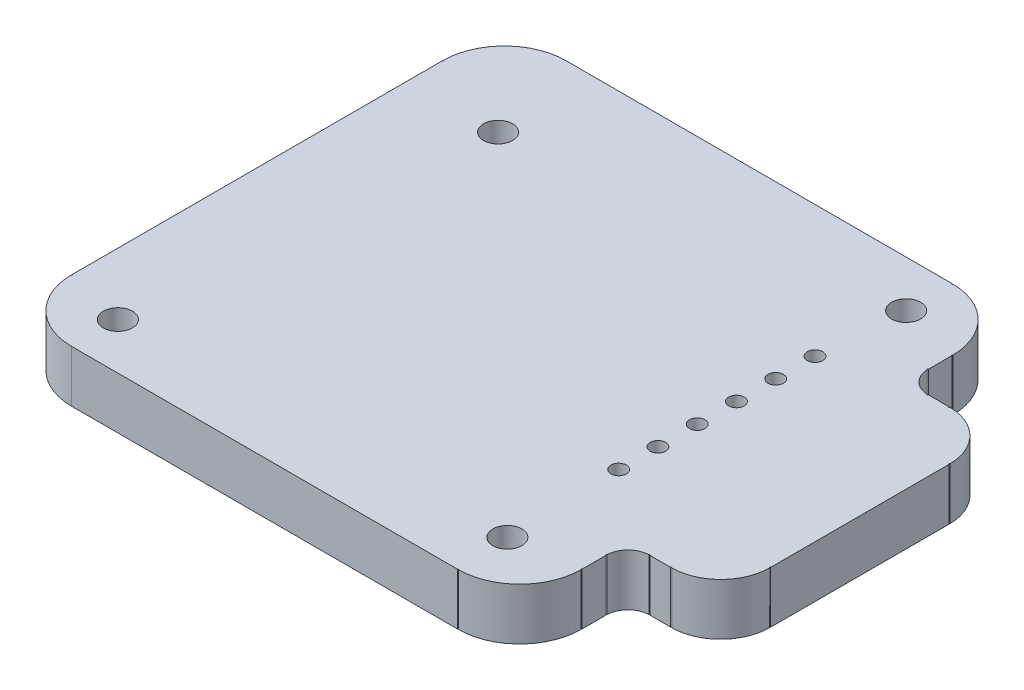
from build123d import *

# Parameters (mm, degrees)
SKETCH1_R           = 0.46989906
SKETCH1_R_2         = 0.2499995
BOSS_EXTRUDE1_DEPTH = 1.6764


with BuildPart() as part:
    # Sketch1 → Boss-Extrude1 (new body)
    with BuildSketch(Plane(origin=(0, 0, 0), x_dir=(1, 0, 0), z_dir=(0, 1, 0))):
        with BuildLine():
            Line((73.134188992, 51.586783601), (72.472390316, 51.586783601))
            ThreePointArc((72.472390316, 51.586783601), (72.466796066, 51.573277888), (72.453290354, 51.567683639))
            ThreePointArc((72.453290354, 51.567683639), (72.439692672, 51.573370488), (72.434192176, 51.587044615))
            ThreePointArc((72.434192176, 51.587044615), (71.958321344, 51.791813191), (71.753552768, 52.267684022))
            ThreePointArc((71.753552768, 52.267684022), (71.739878641, 52.273184519), (71.734191792, 52.286782201))
            ThreePointArc((71.734191792, 52.286782201), (71.739786041, 52.300287913), (71.753291754, 52.305882163))
            Line((71.753291754, 52.305882163), (71.753291754, 53.067680639))
            ThreePointArc((71.753291754, 53.067680639), (71.739786041, 53.073274888), (71.734191792, 53.086780601))
            ThreePointArc((71.734191792, 53.086780601), (71.73975368, 53.100253874), (71.753200111, 53.105880343))
            ThreePointArc((71.753200111, 53.105880343), (71.167492925, 54.500977772), (69.772395496, 55.086684958))
            ThreePointArc((69.772395496, 55.086684958), (69.766769027, 55.073238527), (69.753295754, 55.067676639))
            ThreePointArc((69.753295754, 55.067676639), (69.739790041, 55.073270888), (69.734195792, 55.086776601))
            Line((69.734195792, 55.086776601), (57.253320754, 55.086776601))
            ThreePointArc((57.253320754, 55.086776601), (55.845892561, 54.507714506), (55.253416396, 53.105880343))
            ThreePointArc((55.253416396, 53.105880343), (55.266862828, 53.100253874), (55.272424716, 53.086780601))
            ThreePointArc((55.272424716, 53.086780601), (55.266830466, 53.073274888), (55.253324754, 53.067680639))
            Line((55.253324754, 53.067680639), (55.253324754, 41.105904563))
            ThreePointArc((55.253324754, 41.105904563), (55.266830466, 41.100310313), (55.272424716, 41.086804601))
            ThreePointArc((55.272424716, 41.086804601), (55.266862828, 41.073331328), (55.253416396, 41.067704859))
            ThreePointArc((55.253416396, 41.067704859), (55.845892561, 39.665870695), (57.253320754, 39.086808601))
            Line((57.253320754, 39.086808601), (69.734195792, 39.086808601))
            ThreePointArc((69.734195792, 39.086808601), (69.739790041, 39.100314313), (69.753295754, 39.105908563))
            ThreePointArc((69.753295754, 39.105908563), (69.766769027, 39.100346675), (69.772395496, 39.086900243))
            ThreePointArc((69.772395496, 39.086900243), (71.167492925, 39.672607429), (71.753200111, 41.067704859))
            ThreePointArc((71.753200111, 41.067704859), (71.73975368, 41.073331328), (71.734191792, 41.086804601))
            ThreePointArc((71.734191792, 41.086804601), (71.739786041, 41.100310313), (71.753291754, 41.105904563))
            Line((71.753291754, 41.105904563), (71.753291754, 41.867703039))
            ThreePointArc((71.753291754, 41.867703039), (71.739786041, 41.873297288), (71.734191792, 41.886803001))
            ThreePointArc((71.734191792, 41.886803001), (71.739878641, 41.900400683), (71.753552768, 41.905901179))
            ThreePointArc((71.753552768, 41.905901179), (71.958321344, 42.381772011), (72.434192176, 42.586540587))
            ThreePointArc((72.434192176, 42.586540587), (72.439692672, 42.600214713), (72.453290354, 42.605901563))
            ThreePointArc((72.453290354, 42.605901563), (72.466796066, 42.600307313), (72.472390316, 42.586801601))
            Line((72.472390316, 42.586801601), (73.134188992, 42.586801601))
            ThreePointArc((73.134188992, 42.586801601), (73.139783241, 42.600307313), (73.153288954, 42.605901563))
            ThreePointArc((73.153288954, 42.605901563), (73.166754144, 42.600347714), (73.172388573, 42.586916043))
            ThreePointArc((73.172388573, 42.586916043), (74.284646691, 43.055440663), (74.753171311, 44.167698782))
            ThreePointArc((74.753171311, 44.167698782), (74.73973964, 44.173333211), (74.734185792, 44.186798401))
            ThreePointArc((74.734185792, 44.186798401), (74.739780041, 44.200304113), (74.753285754, 44.205898363))
            Line((74.753285754, 44.205898363), (74.753285754, 49.967686839))
            ThreePointArc((74.753285754, 49.967686839), (74.739780041, 49.973281088), (74.734185792, 49.986786801))
            ThreePointArc((74.734185792, 49.986786801), (74.73973964, 50.000251991), (74.753171311, 50.00588642))
            ThreePointArc((74.753171311, 50.00588642), (74.284646691, 51.118144538), (73.172388573, 51.586669158))
            ThreePointArc((73.172388573, 51.586669158), (73.166754144, 51.573237487), (73.153288954, 51.567683639))
            ThreePointArc((73.153288954, 51.567683639), (73.139783241, 51.573277888), (73.134188992, 51.586783601))
        make_face()
        with Locations((57.253320754, 40.586805601)):
            Circle(SKETCH1_R, mode=Mode.SUBTRACT)
        with Locations((69.653295954, 40.786805201)):
            Circle(SKETCH1_R, mode=Mode.SUBTRACT)
        with Locations((69.553296154, 44.486797801)):
            Circle(SKETCH1_R_2, mode=Mode.SUBTRACT)
        with Locations((69.553296154, 45.756795261)):
            Circle(SKETCH1_R_2, mode=Mode.SUBTRACT)
        with Locations((69.553296154, 47.026792721)):
            Circle(SKETCH1_R_2, mode=Mode.SUBTRACT)
        with Locations((58.153318954, 51.986782801)):
            Circle(SKETCH1_R, mode=Mode.SUBTRACT)
        with Locations((69.553296154, 48.296790181)):
            Circle(SKETCH1_R_2, mode=Mode.SUBTRACT)
        with Locations((69.553296154, 49.566787641)):
            Circle(SKETCH1_R_2, mode=Mode.SUBTRACT)
        with Locations((69.553296154, 50.836785101)):
            Circle(SKETCH1_R_2, mode=Mode.SUBTRACT)
        with Locations((69.753295754, 53.586779601)):
            Circle(SKETCH1_R, mode=Mode.SUBTRACT)
    extrude(amount=BOSS_EXTRUDE1_DEPTH)


solid = part.part
